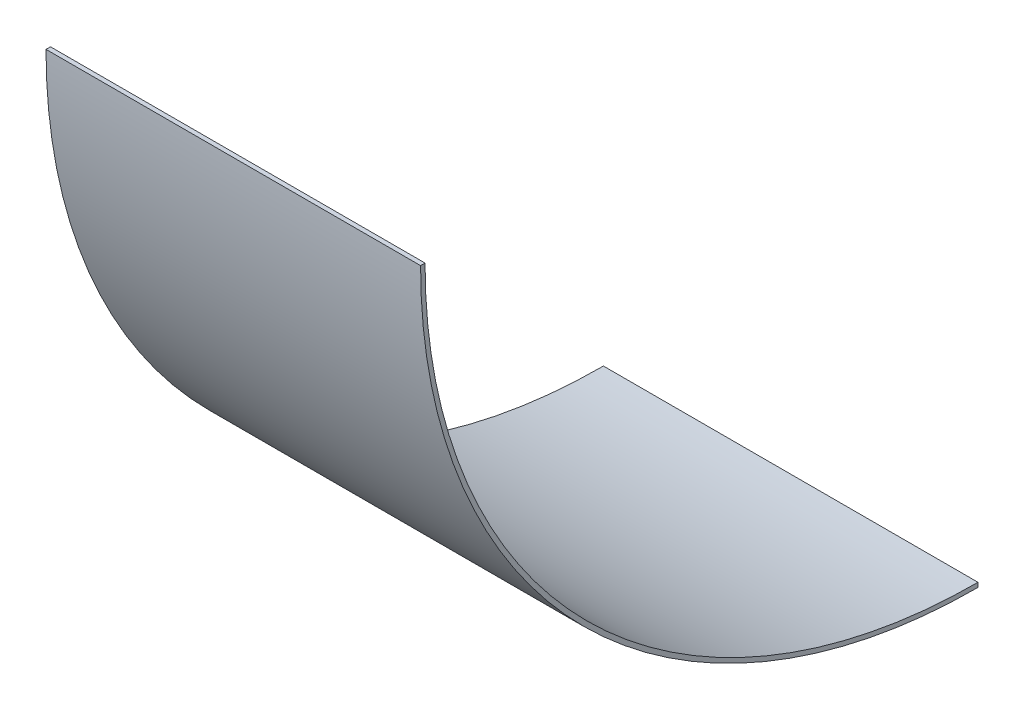
from build123d import *

# Parameters (mm, degrees)
EXTRUDE_THIN1_DEPTH = 133.35


with BuildPart() as part:
    # Sketch1 → Extrude-Thin1 (new body)
    with BuildSketch(Plane(origin=(0, 0, 0), x_dir=(0, 0, -1), z_dir=(1, 0, 0))):
        with BuildLine():
            ThreePointArc((-196.85, 0), (-139.193969877, -139.193969877), (0, -196.85))
            Line((0, -196.85), (0, -198.4375))
            ThreePointArc((0, -198.4375), (-140.316501892, -140.316501892), (-198.4375, 0))
            Line((-198.4375, 0), (-196.85, 0))
        make_face()
    extrude(amount=EXTRUDE_THIN1_DEPTH)


solid = part.part
